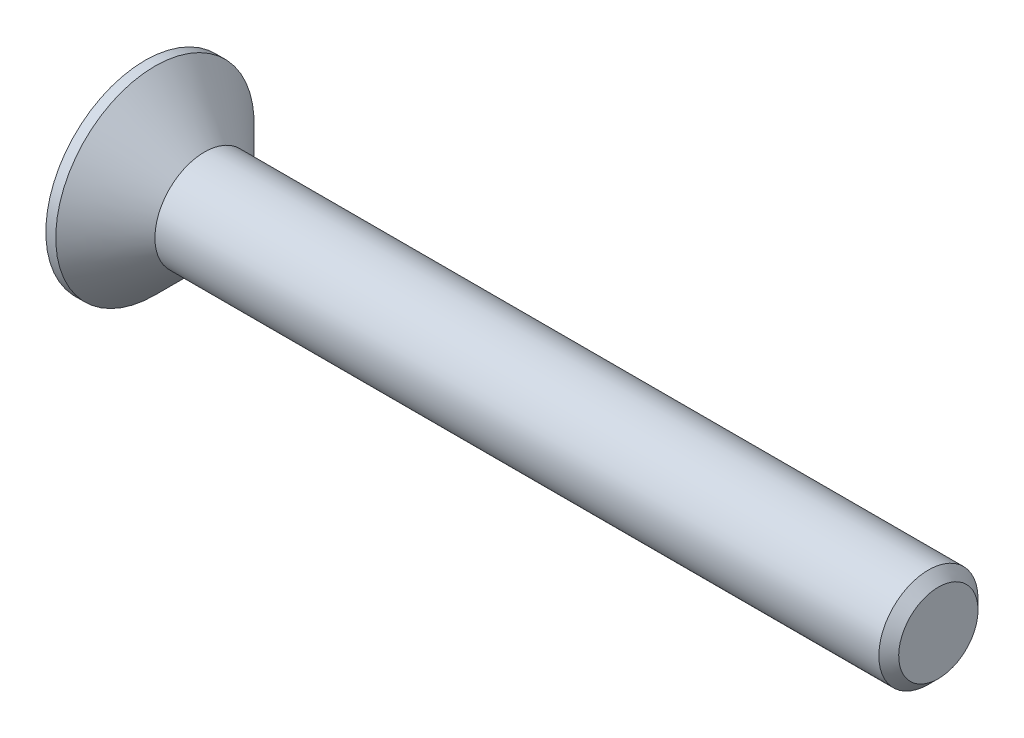
from build123d import *

# Parameters (mm, degrees)
CHAMFER1_SIZE      = 0.2
CUT_EXTRUDE1_DEPTH = 0.75


with BuildPart() as part:
    # Sketch1 → Revolve1 (revolve)
    with BuildSketch(Plane.XY):
        Polygon((0, 1), (-1, 2), (-1.2, 2), (-1.2, 0), (14.8, 0), (14.8, 1), align=None)
    revolve(axis=Axis((-1.2, 0, 0), (1, 0, 0)))

    # Chamfer1
    chamfer1_edges = [part.edges().sort_by_distance(p)[0] for p in [
        (14.8, -1, 0),
    ]]
    chamfer(chamfer1_edges, length=CHAMFER1_SIZE)

    # Sketch2 → Cut-Extrude1 (cut)
    with BuildSketch(Plane.ZY.offset(1.2)):
        Polygon((-0.75055535, 0), (-0.375277675, -0.65), (0.375277675, -0.65), (0.75055535, 0), (0.375277675, 0.65), (-0.375277675, 0.65), align=None)
    extrude(amount=-CUT_EXTRUDE1_DEPTH, mode=Mode.SUBTRACT)


solid = part.part
